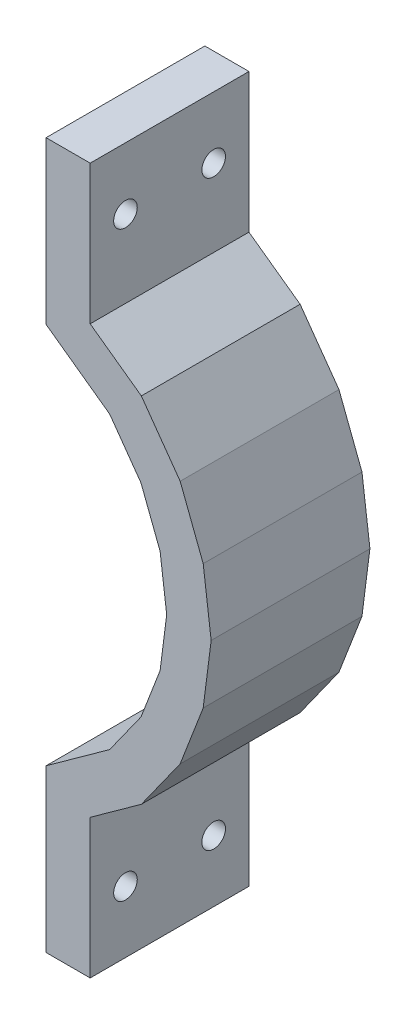
from build123d import *

# Parameters (mm, degrees)
BOSS_EXTRUDE1_DEPTH  = 22.86
M3_CLEARANCE_HOLE1_D = 3.4


with BuildPart() as part:
    # Model → Boss-Extrude1 (new body)
    with BuildSketch(Plane.XY):
        Polygon((35.35946236, 21.996272555), (44.513095611, 15.400697433), (49.027368987, 9.071379605), (51.777733141, 1.917532085), (52.724150942, -5.518132067), (51.777733141, -12.953796218), (49.027368987, -20.107643738), (44.513095611, -26.436961567), (35.35946236, -33.032536689), (35.35946236, -56.318132067), (41.70946236, -56.318132067), (41.70946236, -36.283791365), (49.074837222, -30.976731111), (54.665181836, -23.138688335), (57.980059071, -14.51651143), (59.125380623, -5.518132067), (57.980059071, 3.480247297), (54.665181836, 12.102424201), (49.074837222, 19.940466977), (41.70946236, 25.247527231), (41.70946236, 45.281867933), (35.35946236, 45.281867933), align=None)
    extrude(amount=BOSS_EXTRUDE1_DEPTH)

    # M3 Clearance Hole1 (through all)
    with Locations(Plane(origin=(41.70946236, 0, 0), x_dir=(0, 0, -1), z_dir=(1, 0, 0))):
        with Locations((-17.78, 36.391867933), (-5.08, 36.391867933), (-17.78, -47.428132067), (-5.08, -47.428132067)):
            Hole(M3_CLEARANCE_HOLE1_D / 2)


solid = part.part
